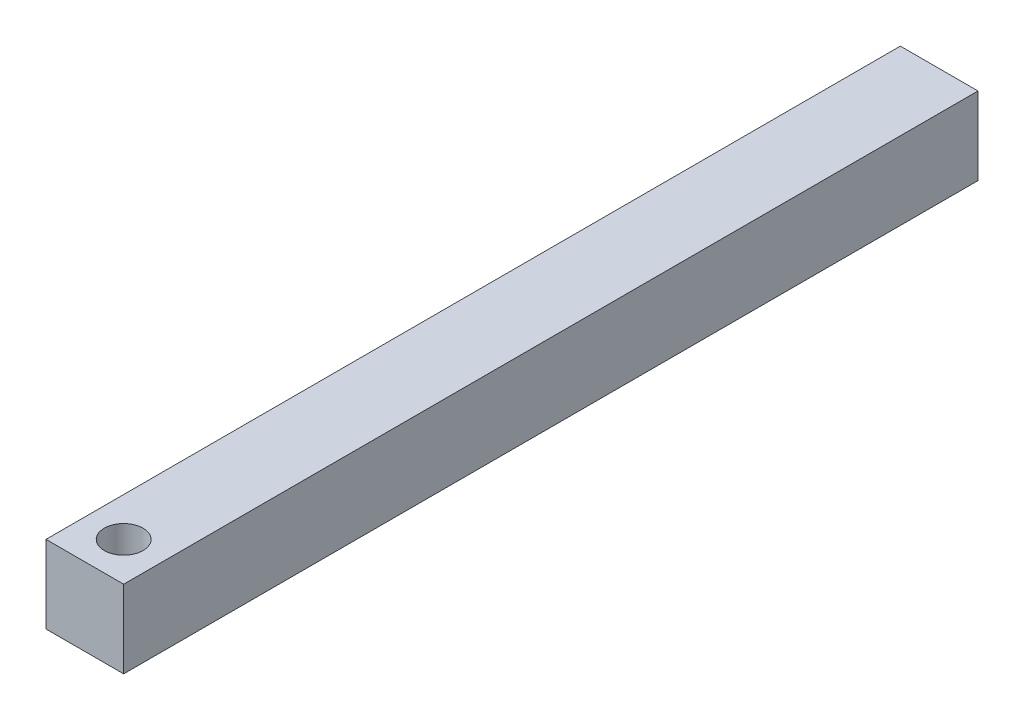
from build123d import *

# Parameters (mm, degrees)
SKETCH1_W           = 25.4
SKETCH1_H           = 25.4
BOSS_EXTRUDE1_DEPTH = 279.4
SKETCH2_R           = 6.35
CUT_EXTRUDE1_DEPTH  = 26.4


with BuildPart() as part:
    # Sketch1 → Boss-Extrude1 (new body)
    with BuildSketch(Plane.XY):
        with Locations((-12.7, 12.7)):
            Rectangle(SKETCH1_W, SKETCH1_H)
    extrude(amount=BOSS_EXTRUDE1_DEPTH)

    # Sketch2 → Cut-Extrude1 (cut, through all)
    with BuildSketch(Plane(origin=(0, 25.4, 0), x_dir=(1, 0, 0), z_dir=(0, 1, 0))):
        with Locations((-12.7, -266.7)):
            Circle(SKETCH2_R)
    extrude(amount=-CUT_EXTRUDE1_DEPTH, mode=Mode.SUBTRACT)


solid = part.part
